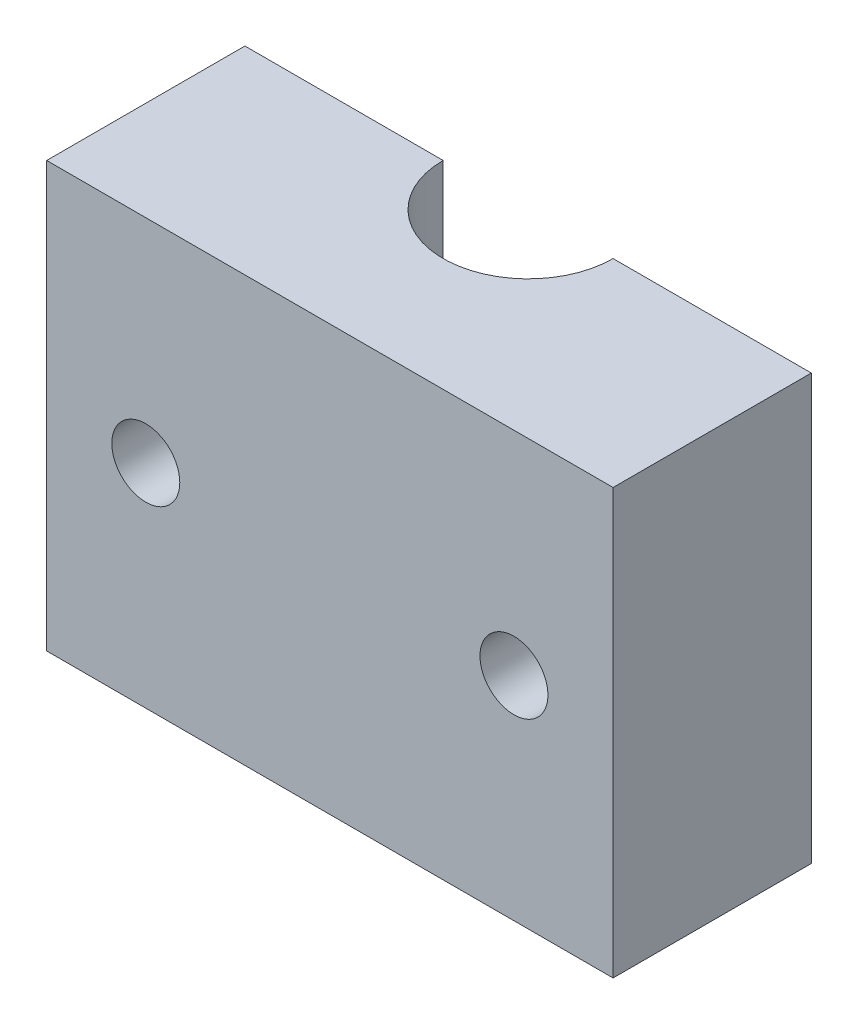
from build123d import *

# Parameters (mm, degrees)
SKETCH1_W          = 20
SKETCH1_H          = 15
EXTRUDE1_DEPTH     = 3.5
SKETCH2_R          = 3
CUT_EXTRUDE1_DEPTH = 16
SKETCH3_R          = 1.2
CUT_EXTRUDE2_DEPTH = 8


with BuildPart() as part:
    # Sketch1 → Extrude1 (new body, symmetric)
    with BuildSketch(Plane.XY):
        Rectangle(SKETCH1_W, SKETCH1_H)
    extrude(amount=EXTRUDE1_DEPTH, both=True)

    # Sketch2 → Cut-Extrude1 (cut, through all)
    with BuildSketch(Plane(origin=(0, 7.5, 0), x_dir=(-1, 0, 0), z_dir=(0, 1, 0))):
        with Locations((0, -3.5)):
            Circle(SKETCH2_R)
    extrude(amount=-CUT_EXTRUDE1_DEPTH, mode=Mode.SUBTRACT)

    # Sketch3 → Cut-Extrude2 (cut, through all)
    with BuildSketch(Plane.XY.offset(3.5)):
        with Locations((-6.5, 0)):
            Circle(SKETCH3_R)
        with Locations((6.5, 0)):
            Circle(SKETCH3_R)
    extrude(amount=-CUT_EXTRUDE2_DEPTH, mode=Mode.SUBTRACT)


solid = part.part
